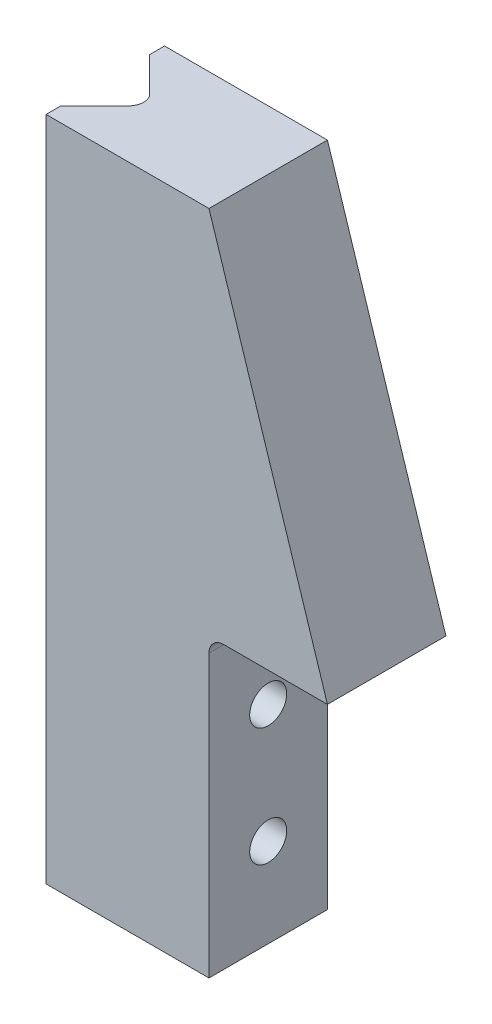
from build123d import *

# Parameters (mm, degrees)
BOSS_EXTRUDE1_DEPTH       = 8
CUT_EXTRUDE1_DEPTH        = 46
M3X0_5_TAPPED_HOLE1_D     = 2.5
M3X0_5_TAPPED_HOLE1_DEPTH = 5
M3X0_5_TAPPED_HOLE1_TIP   = 0.751075774
FILLET1_R                 = 1
FILLET2_R                 = 1


with BuildPart() as part:
    # Sketch1 → Boss-Extrude1 (new body)
    with BuildSketch(Plane.XY):
        Polygon((0, 0), (-8, 0), (-8, -20), (-19, -20), (-19, 25), (-8, 25), align=None)
    extrude(amount=BOSS_EXTRUDE1_DEPTH)

    # Sketch2 → Cut-Extrude1 (cut, through all)
    with BuildSketch(Plane(origin=(0, 25, 0), x_dir=(1, 0, 0), z_dir=(0, 1, 0))):
        Polygon((-19, -4), (-19, -1), (-16, -4), (-19, -7), align=None)
    extrude(amount=-CUT_EXTRUDE1_DEPTH, mode=Mode.SUBTRACT)

    # M3x0.5 Tapped Hole1
    with Locations(Plane(origin=(-8, -6, 4), x_dir=(0, 0, 1), z_dir=(1, 0, 0))):
        with Locations((0, 0), (0, 8)):
            Hole(M3X0_5_TAPPED_HOLE1_D / 2, depth=M3X0_5_TAPPED_HOLE1_DEPTH)
            with Locations((0, 0, -(M3X0_5_TAPPED_HOLE1_DEPTH + M3X0_5_TAPPED_HOLE1_TIP / 2))):  # 118° drill point
                Cone(0, M3X0_5_TAPPED_HOLE1_D / 2, M3X0_5_TAPPED_HOLE1_TIP, mode=Mode.SUBTRACT)

    # Fillet1
    fillet1_edges = [part.edges().sort_by_distance(p)[0] for p in [
        (-16, 2.5, 4),
    ]]
    fillet(fillet1_edges, radius=FILLET1_R)

    # Fillet2
    fillet2_edges = [part.edges().sort_by_distance(p)[0] for p in [
        (-8, 0, 4),
    ]]
    fillet(fillet2_edges, radius=FILLET2_R)


solid = part.part
